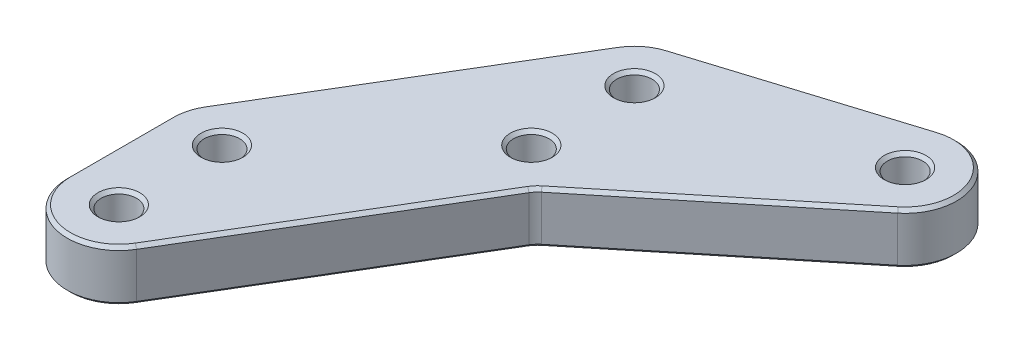
from build123d import *

# Parameters (mm, degrees)
SKETCH1_R           = 2.1828125
BOSS_EXTRUDE1_DEPTH = 3.175
CHAMFER1_SIZE       = 0.396875


with BuildPart() as part:
    # Sketch1 → Boss-Extrude1 (new body, symmetric)
    with BuildSketch(Plane(origin=(0, 0, 0), x_dir=(1, 0, 0), z_dir=(0, 1, 0))):
        with BuildLine():
            Line((-25.4, -19.05), (-25.4, -31.75))
            ThreePointArc((-25.4, -31.75), (-20.745028245, -37.869589794), (-13.604919922, -35.017048047))
            Line((-13.604919922, -35.017048047), (4.519073196, -4.810392851))
            ThreePointArc((4.519073196, -4.810392851), (4.841622185, -4.365295225), (5.236106863, -3.98250078))
            Line((5.236106863, -3.98250078), (29.411012744, 15.71466781))
            ThreePointArc((29.411012744, 15.71466781), (30.992963694, 23.644368325), (23.505953794, 26.698447861))
            Line((23.505953794, 26.698447861), (-1.894046206, 18.760947861))
            ThreePointArc((-1.894046206, 18.760947861), (-3.926469495, 17.690524752), (-5.445080078, 15.967048047))
            Line((-5.445080078, 15.967048047), (-24.495080078, -15.782951953))
            ThreePointArc((-24.495080078, -15.782951953), (-25.169589794, -17.354971755), (-25.4, -19.05))
        make_face()
        Circle(SKETCH1_R, mode=Mode.SUBTRACT)
        with Locations((0, 12.7)):
            Circle(SKETCH1_R, mode=Mode.SUBTRACT)
        with Locations((-19.05, -19.05)):
            Circle(SKETCH1_R, mode=Mode.SUBTRACT)
        with Locations((-19.05, -31.75)):
            Circle(SKETCH1_R, mode=Mode.SUBTRACT)
        with Locations((25.4, 20.6375)):
            Circle(SKETCH1_R, mode=Mode.SUBTRACT)
    extrude(amount=BOSS_EXTRUDE1_DEPTH, both=True)

    # Chamfer1
    chamfer1_edges = [part.edges().sort_by_distance(p)[0] for p in [
        (-4.542923363, -3.175, 19.913720449),
        (-20.745028245, -3.175, 37.869589794),
        (-25.4, -3.175, 25.4),
        (-25.169589794, -3.175, 17.354971755),
        (-14.970080078, -3.175, -0.092048047),
        (-3.926469495, -3.175, -17.690524752),
        (10.805953794, -3.175, -22.729697861),
        (30.992963694, 3.175, -23.644368325),
        (30.992963694, -3.175, -23.644368325),
        (17.323559803, -3.175, -5.866083515),
        (4.841622185, -3.175, 4.365295225),
        (10.805953794, 3.175, -22.729697861),
        (-3.926469495, 3.175, -17.690524752),
        (-14.970080078, 3.175, -0.092048047),
        (-2.1828125, -3.175, 0),
        (-2.1828125, 3.175, 0),
        (-25.169589794, 3.175, 17.354971755),
        (-2.1828125, -3.175, -12.7),
        (-2.1828125, 3.175, -12.7),
        (-25.4, 3.175, 25.4),
        (-21.2328125, -3.175, 19.05),
        (-21.2328125, 3.175, 19.05),
        (-20.745028245, 3.175, 37.869589794),
        (-21.2328125, -3.175, 31.75),
        (-21.2328125, 3.175, 31.75),
        (-4.542923363, 3.175, 19.913720449),
        (23.2171875, -3.175, -20.6375),
        (23.2171875, 3.175, -20.6375),
        (4.841622185, 3.175, 4.365295225),
        (17.323559803, 3.175, -5.866083515),
    ]]
    chamfer(chamfer1_edges, length=CHAMFER1_SIZE)


solid = part.part
